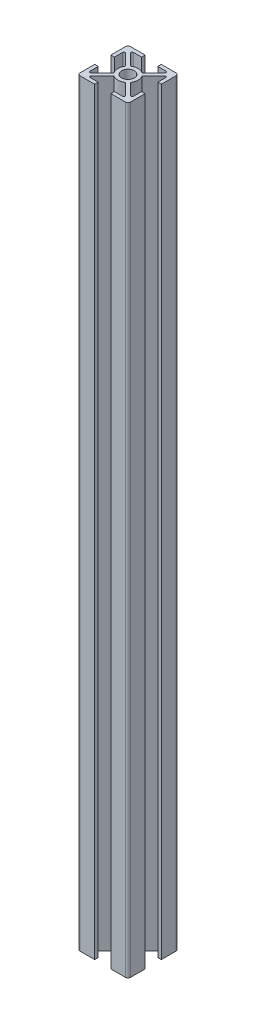
from build123d import *

# Parameters (mm, degrees)
SKETCH1_R           = 2.5
BOSS_EXTRUDE1_DEPTH = 300
FILLET1_R           = 0.5
FILLET2_R           = 1


with BuildPart() as part:
    # Sketch1 → Boss-Extrude1 (new body)
    with BuildSketch(Plane(origin=(0, 0, 0), x_dir=(1, 0, 0), z_dir=(0, 1, 0))):
        with BuildLine():
            Line((3.2, 10), (3.2, 8.6))
            Line((3.2, 8.6), (7.610050506, 8.6))
            Line((7.610050506, 8.6), (2.289805316, 3.27975481))
            ThreePointArc((2.289805316, 3.27975481), (0, 4), (-2.289805316, 3.27975481))
            Line((-2.289805316, 3.27975481), (-7.610050506, 8.6))
            Line((-7.610050506, 8.6), (-3.2, 8.6))
            Line((-3.2, 8.6), (-3.2, 10))
            Line((-3.2, 10), (-10, 10))
            Line((-10, 10), (-10, 3.2))
            Line((-10, 3.2), (-8.6, 3.2))
            Line((-8.6, 3.2), (-8.6, 7.610050506))
            Line((-8.6, 7.610050506), (-3.27975481, 2.289805316))
            ThreePointArc((-3.27975481, 2.289805316), (-4, 0), (-3.27975481, -2.289805316))
            Line((-3.27975481, -2.289805316), (-8.6, -7.610050506))
            Line((-8.6, -7.610050506), (-8.6, -3.2))
            Line((-8.6, -3.2), (-10, -3.2))
            Line((-10, -3.2), (-10, -10))
            Line((-10, -10), (-3.2, -10))
            Line((-3.2, -10), (-3.2, -8.6))
            Line((-3.2, -8.6), (-7.610050506, -8.6))
            Line((-7.610050506, -8.6), (-2.289805316, -3.27975481))
            ThreePointArc((-2.289805316, -3.27975481), (0, -4), (2.289805316, -3.27975481))
            Line((2.289805316, -3.27975481), (7.610050506, -8.6))
            Line((7.610050506, -8.6), (3.2, -8.6))
            Line((3.2, -8.6), (3.2, -10))
            Line((3.2, -10), (10, -10))
            Line((10, -10), (10, -3.2))
            Line((10, -3.2), (8.6, -3.2))
            Line((8.6, -3.2), (8.6, -7.610050506))
            Line((8.6, -7.610050506), (3.27975481, -2.289805316))
            ThreePointArc((3.27975481, -2.289805316), (4, 0), (3.27975481, 2.289805316))
            Line((3.27975481, 2.289805316), (8.6, 7.610050506))
            Line((8.6, 7.610050506), (8.6, 3.2))
            Line((8.6, 3.2), (10, 3.2))
            Line((10, 3.2), (10, 10))
            Line((10, 10), (3.2, 10))
        make_face()
        Circle(SKETCH1_R, mode=Mode.SUBTRACT)
    extrude(amount=BOSS_EXTRUDE1_DEPTH)

    # Fillet1
    fillet1_edges = [part.edges().sort_by_distance(p)[0] for p in [
        (8.6, 150, -7.610050506),
        (8.6, 150, 7.610050506),
        (7.610050506, 150, 8.6),
        (-7.610050506, 150, 8.6),
        (-8.6, 150, 7.610050506),
        (-8.6, 150, -7.610050506),
        (-7.610050506, 150, -8.6),
        (7.610050506, 150, -8.6),
    ]]
    fillet(fillet1_edges, radius=FILLET1_R)

    # Fillet2
    fillet2_edges = [part.edges().sort_by_distance(p)[0] for p in [
        (10, 150, 10),
        (-10, 150, 10),
        (-10, 150, -10),
        (10, 150, -10),
    ]]
    fillet(fillet2_edges, radius=FILLET2_R)


solid = part.part
